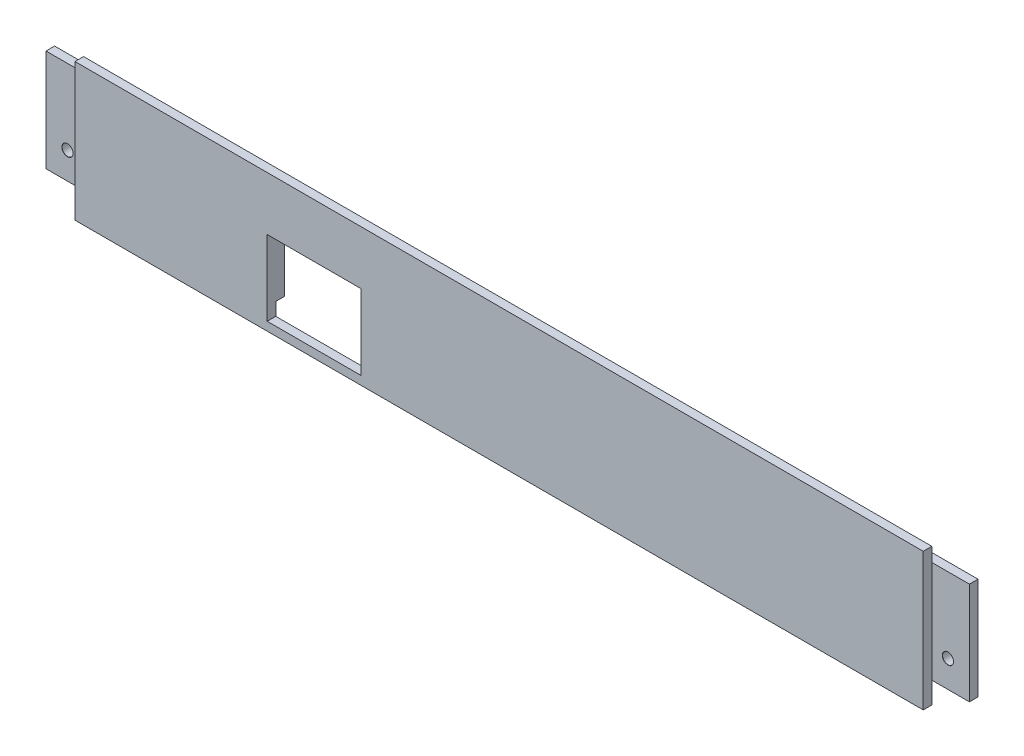
from build123d import *

# Parameters (mm, degrees)
SKETCH1_W                                = 158
SKETCH1_H                                = 25.6
BOSS_EXTRUDE1_DEPTH                      = 1.6
SKETCH2_W                                = 172
SKETCH2_H                                = 19
BOSS_EXTRUDE2_DEPTH                      = 1.6
TAP_DRILL_FOR_M2_5X0_45_TAP3_D           = 2.05
TAP_DRILL_FOR_M2_5X0_45_TAP3_CSINK_D     = 2.1
TAP_DRILL_FOR_M2_5X0_45_TAP3_CSINK_ANGLE = 90
SKETCH7_W                                = 7
SKETCH7_H                                = 7
SKETCH7_R                                = 1.3
BOSS_EXTRUDE3_DEPTH                      = 2.5
BOSS_EXTRUDE3_2_DEPTH                    = 2.5
SKETCH8_W                                = 17.5
SKETCH8_H                                = 14
CUT_EXTRUDE1_DEPTH                       = 2.6
CUT_EXTRUDE1_DEPTH_BACK                  = 8


with BuildPart() as part:
    # Sketch1 → Boss-Extrude1 (new body)
    with BuildSketch(Plane.XY):
        with Locations((0, 12.8)):
            Rectangle(SKETCH1_W, SKETCH1_H)
    extrude(amount=BOSS_EXTRUDE1_DEPTH)

    # Sketch2 → Boss-Extrude2 (add)
    with BuildSketch(Plane.XY):
        with Locations((0, 13.5)):
            Rectangle(SKETCH2_W, SKETCH2_H)
    extrude(amount=-BOSS_EXTRUDE2_DEPTH)

    # Tap Drill for M2.5x0.45 Tap3 (through all)
    with Locations(Plane(origin=(-82, 9, 0), x_dir=(1, 0, 0), z_dir=(0, 0, 1))):
        with Locations((0, 0), (164, 0)):
            CounterSinkHole(TAP_DRILL_FOR_M2_5X0_45_TAP3_D / 2, TAP_DRILL_FOR_M2_5X0_45_TAP3_CSINK_D / 2, counter_sink_angle=TAP_DRILL_FOR_M2_5X0_45_TAP3_CSINK_ANGLE)

    # Sketch8 → Cut-Extrude1 (cut, two sides)
    with BuildSketch(Plane.XY) as cut_extrude1_sk:
        with Locations((-34.45, 8.6)):
            Rectangle(SKETCH8_W, SKETCH8_H)
    extrude(amount=CUT_EXTRUDE1_DEPTH, mode=Mode.SUBTRACT)
    extrude(cut_extrude1_sk.sketch, amount=-CUT_EXTRUDE1_DEPTH_BACK, mode=Mode.SUBTRACT)


with BuildPart() as body_2:
    # Sketch7 → Boss-Extrude3 (new body)
    with BuildSketch(Plane(origin=(0, 1.6, 0), x_dir=(1, 0, 0), z_dir=(0, 1, 0))):
        with Locations((-57.4, 3.5)):
            Rectangle(SKETCH7_W, SKETCH7_H)
        with Locations((-56.9, 4.51)):
            Circle(SKETCH7_R, mode=Mode.SUBTRACT)
    extrude(amount=BOSS_EXTRUDE3_DEPTH)


with BuildPart() as body_3:
    # Sketch7 → Boss-Extrude3 2 (new body)
    with BuildSketch(Plane(origin=(0, 1.6, 0), x_dir=(1, 0, 0), z_dir=(0, 1, 0))):
        with Locations((67.4, 3.5)):
            Rectangle(SKETCH7_W, SKETCH7_H)
        with Locations((66.9, 4.51)):
            Circle(SKETCH7_R, mode=Mode.SUBTRACT)
    extrude(amount=BOSS_EXTRUDE3_2_DEPTH)


solid = Compound([part.part, body_2.part, body_3.part])
